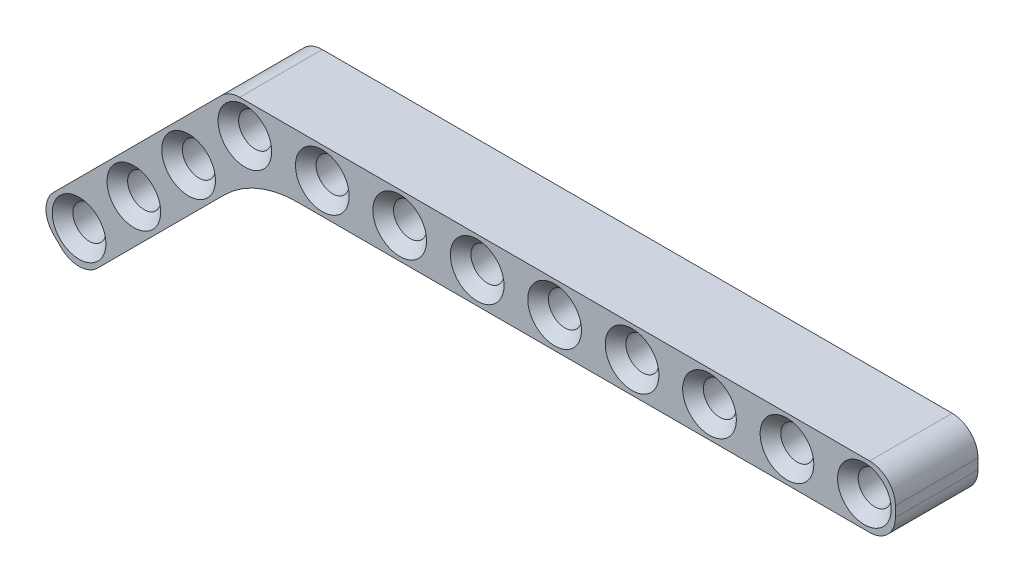
from build123d import *

# Parameters (mm, degrees)
SKETCH1_R           = 1.6
BOSS_EXTRUDE1_DEPTH = 8
CHAMFER1_SIZE       = 1
SKETCH2_R           = 1.6
BOSS_EXTRUDE3_DEPTH = 8
FILLET1_R           = 10
CHAMFER2_SIZE       = 1
CHAMFER3_SIZE       = 1
CHAMFER4_SIZE       = 1


with BuildPart() as part:
    # Sketch1 → Boss-Extrude1 (new body)
    with BuildSketch(Plane.XY):
        with BuildLine():
            Line((-0.5, 3), (60.5, 3))
            ThreePointArc((60.5, 3), (62.267766953, 2.267766953), (63, 0.5))
            Line((63, 0.5), (63, -0.5))
            ThreePointArc((63, -0.5), (62.267766953, -2.267766953), (60.5, -3))
            Line((60.5, -3), (-0.5, -3))
            ThreePointArc((-0.5, -3), (-2.267766953, -2.267766953), (-3, -0.5))
            Line((-3, -0.5), (-3, 0.5))
            ThreePointArc((-3, 0.5), (-2.267766953, 2.267766953), (-0.5, 3))
        make_face()
        Circle(SKETCH1_R, mode=Mode.SUBTRACT)
        with Locations((7.5, 0)):
            Circle(SKETCH1_R, mode=Mode.SUBTRACT)
        with Locations((15, 0)):
            Circle(SKETCH1_R, mode=Mode.SUBTRACT)
        with Locations((22.5, 0)):
            Circle(SKETCH1_R, mode=Mode.SUBTRACT)
        with Locations((30, 0)):
            Circle(SKETCH1_R, mode=Mode.SUBTRACT)
        with Locations((37.5, 0)):
            Circle(SKETCH1_R, mode=Mode.SUBTRACT)
        with Locations((45, 0)):
            Circle(SKETCH1_R, mode=Mode.SUBTRACT)
        with Locations((52.5, 0)):
            Circle(SKETCH1_R, mode=Mode.SUBTRACT)
        with Locations((60, 0)):
            Circle(SKETCH1_R, mode=Mode.SUBTRACT)
    extrude(amount=BOSS_EXTRUDE1_DEPTH)

    # Chamfer1
    chamfer1_edges = [part.edges().sort_by_distance(p)[0] for p in [
        (-1.6, 0, 0),
        (-1.6, 0, 8),
        (5.9, 0, 0),
        (5.9, 0, 8),
        (13.4, 0, 0),
        (13.4, 0, 8),
        (20.9, 0, 0),
        (20.9, 0, 8),
        (28.4, 0, 0),
        (28.4, 0, 8),
    ]]
    chamfer(chamfer1_edges, length=CHAMFER1_SIZE)

    # Sketch2 → Boss-Extrude3 (add)
    with BuildSketch(Plane.XY.offset(8)):
        with BuildLine():
            ThreePointArc((-3, 0.5), (-2.809698831, 1.456708581), (-2.267766953, 2.267766953))
            Line((-2.267766953, 2.267766953), (-18.529200529, -13.993666623))
            ThreePointArc((-18.529200529, -13.993666623), (-19.261433576, -15.761433576), (-18.529200529, -17.529200529))
            Line((-18.529200529, -17.529200529), (-17.822093748, -18.23630731))
            ThreePointArc((-17.822093748, -18.23630731), (-16.054326795, -18.968540357), (-14.286559842, -18.23630731))
            Line((-14.286559842, -18.23630731), (0.949747468, -3))
            Line((0.949747468, -3), (-0.5, -3))
            ThreePointArc((-0.5, -3), (-2.267766953, -2.267766953), (-3, -0.5))
            Line((-3, -0.5), (-3, 0.5))
        make_face()
        with Locations((-16.054326795, -15.761433576)):
            Circle(SKETCH2_R, mode=Mode.SUBTRACT)
        with Locations((-10.751025936, -10.458132717)):
            Circle(SKETCH2_R, mode=Mode.SUBTRACT)
        with Locations((-5.447725077, -5.154831858)):
            Circle(SKETCH2_R, mode=Mode.SUBTRACT)
    extrude(amount=-BOSS_EXTRUDE3_DEPTH)

    # Fillet1
    fillet1_edges = [part.edges().sort_by_distance(p)[0] for p in [
        (0.949747468, -3, 4),
    ]]
    fillet(fillet1_edges, radius=FILLET1_R)

    # Chamfer2
    chamfer2_edges = [part.edges().sort_by_distance(p)[0] for p in [
        (-17.654326795, -15.761433576, 0),
        (-17.654326795, -15.761433576, 8),
        (-12.351025936, -10.458132717, 8),
        (-7.047725077, -5.154831858, 8),
        (-7.047725077, -5.154831858, 0),
        (-12.351025936, -10.458132717, 0),
    ]]
    chamfer(chamfer2_edges, length=CHAMFER2_SIZE)

    # Chamfer3
    chamfer3_edges = [part.edges().sort_by_distance(p)[0] for p in [
        (35.9, 0, 0),
        (35.9, 0, 8),
        (43.4, 0, 0),
        (43.4, 0, 8),
    ]]
    chamfer(chamfer3_edges, length=CHAMFER3_SIZE)

    # Chamfer4
    chamfer4_edges = [part.edges().sort_by_distance(p)[0] for p in [
        (50.9, 0, 0),
        (50.9, 0, 8),
        (58.4, 0, 0),
        (58.4, 0, 8),
    ]]
    chamfer(chamfer4_edges, length=CHAMFER4_SIZE)


solid = part.part
